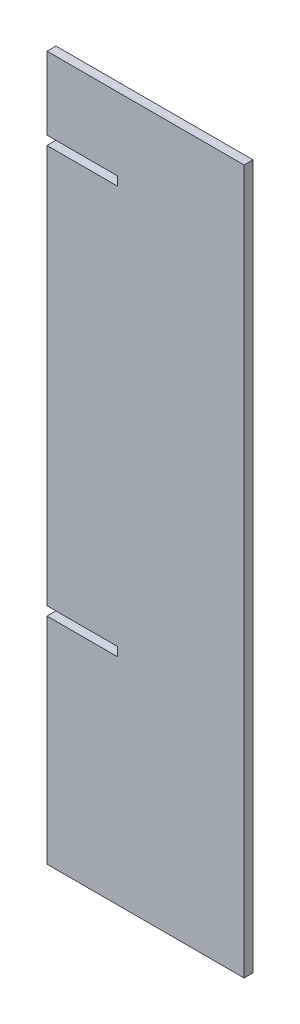
from build123d import *

# Parameters (mm, degrees)
SKETCH1_W           = 70
SKETCH1_H           = 250
BOSS_EXTRUDE1_DEPTH = 3.175
SKETCH2_W           = 25
SKETCH2_H           = 3.175
CUT_EXTRUDE1_DEPTH  = 3.175


with BuildPart() as part:
    # Sketch1 → Boss-Extrude1 (new body)
    with BuildSketch(Plane.XY):
        Rectangle(SKETCH1_W, SKETCH1_H)
    extrude(amount=BOSS_EXTRUDE1_DEPTH)

    # Sketch2 → Cut-Extrude1 (cut)
    with BuildSketch(Plane.XY.offset(3.175)):
        with Locations((-22.5, 97.5925)):
            Rectangle(SKETCH2_W, SKETCH2_H)
        with Locations((-22.5, -47.1075)):
            Rectangle(SKETCH2_W, SKETCH2_H)
    extrude(amount=-CUT_EXTRUDE1_DEPTH, mode=Mode.SUBTRACT)


solid = part.part
